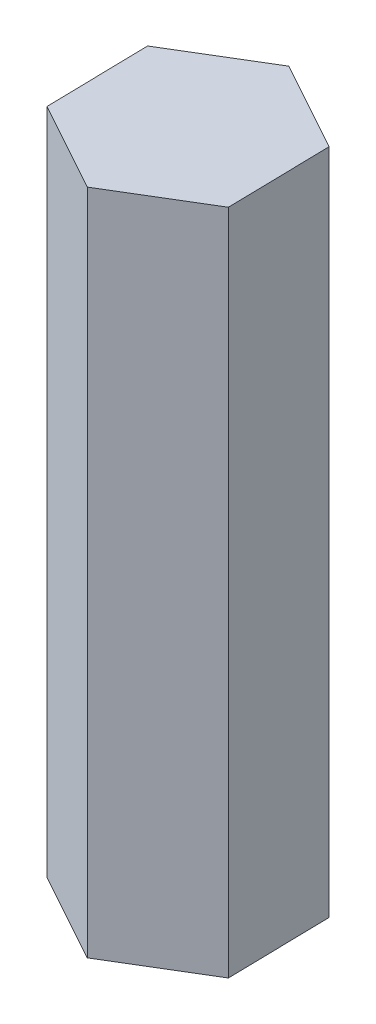
from build123d import *

# Parameters (mm, degrees)
EXTRUDE_1_DEPTH = 30


with BuildPart() as part:
    # 草图1 → 凸台-拉伸1 (new body)
    with BuildSketch(Plane(origin=(0, 0, 0), x_dir=(1, 0, 0), z_dir=(0, 1, 0))):
        Polygon((4.045125348, -2.229415675), (3.953293284, 2.388473476), (-0.091832064, 4.61788915), (-4.045125348, 2.229415675), (-3.953293284, -2.388473476), (0.091832064, -4.61788915), align=None)
    extrude(amount=EXTRUDE_1_DEPTH)


solid = part.part
